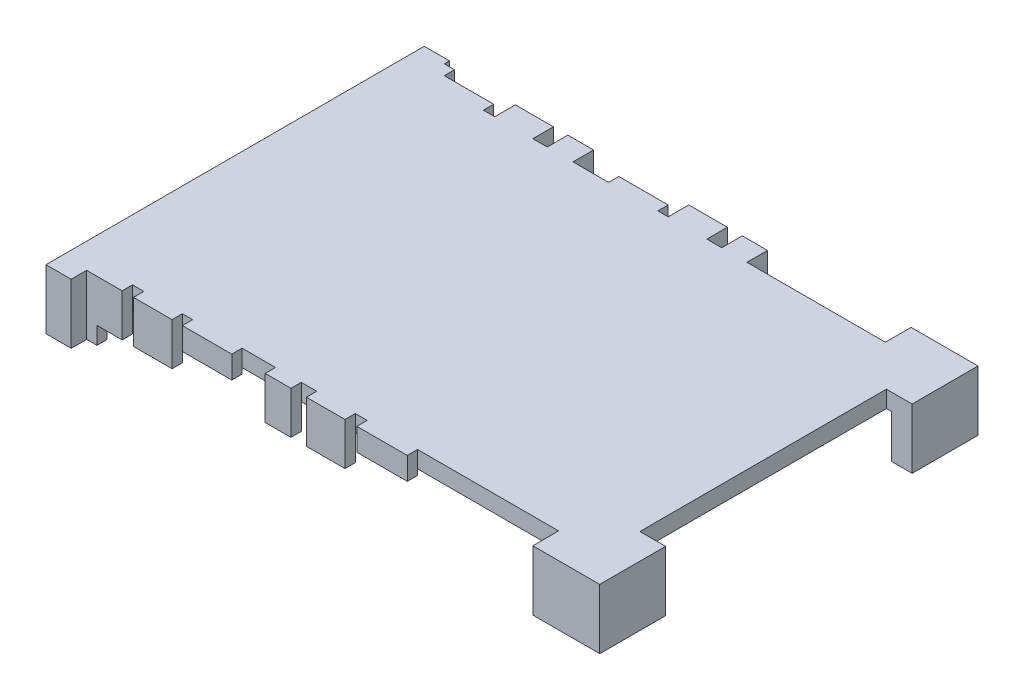
from build123d import *

# Parameters (mm, degrees)
CORNERS_DEPTH                      = 8.4
CORNERS_2_DEPTH                    = 8.4
SKETCH2_W                          = 102.6
SKETCH2_H                          = 63.5
MASTER_DEPTH                       = 3
SKETCH3_W                          = 4.9
SKETCH3_H                          = 73.5
END_TAB_DEPTH                      = 8.36
END_TAB_DEPTH_BACK                 = 3.27
SKETCH4_W                          = 3.2
SKETCH4_H                          = 6.4
MALE_CONNECTORS_DEPTH              = 1.65
SKETCH5_W                          = 9.6
SKETCH5_H                          = 2
SKETCH5_W_2                        = 7.4
SKETCH5_H_2                        = 4
SKETCH5_W_3                        = 5
SKETCH5_W_4                        = 7.5
SKETCH5_W_5                        = 4.9
RIGHT_TERMINALS_DEPTH              = 5
RIGHT_TERMINALS_DEPTH_BACK         = 3.27
SKETCH7_W                          = 4.9
SKETCH7_H                          = 2
LEFT_TERMINALS_DEPTH               = 5
LEFT_TERMINALS_DEPTH_BACK          = 3.27
SKETCH7_W_2                        = 7.5
LEFT_TERMINALS_2_DEPTH             = 5
LEFT_TERMINALS_2_DEPTH_BACK        = 3.27
SKETCH7_W_3                        = 9.6
LEFT_TERMINALS_3_DEPTH             = 5
LEFT_TERMINALS_3_DEPTH_BACK        = 3.27
SKETCH7_W_4                        = 5
LEFT_TERMINALS_4_DEPTH             = 5
LEFT_TERMINALS_4_DEPTH_BACK        = 3.27
LEFT_TERMINALS_5_DEPTH             = 5
LEFT_TERMINALS_5_DEPTH_BACK        = 3.27
SKETCH7_W_5                        = 9.8
LEFT_TERMINALS_6_DEPTH             = 5
LEFT_TERMINALS_6_DEPTH_BACK        = 3.27
SKETCH8_W                          = 9.6
SKETCH8_H                          = 2
GOLD_PLATE_ADJUSTMENTS_RIGHT_DEPTH = 3.9
SKETCH9_W                          = 9.6
SKETCH9_H                          = 2
SKETCH9_W_2                        = 9.8
GOLD_PLATE_ADJUSTMENTS_LEFT_DEPTH  = 3.9
CORNER_ADJUSTMENT_DEPTH            = 3
SKETCH13_W                         = 97.7
SKETCH13_H                         = 63.5
BOSS_EXTRUDE1_DEPTH                = 0.27
SKETCH14_W                         = 13
SKETCH14_H                         = 12.8
BOSS_EXTRUDE2_DEPTH                = 0.27
SKETCH17_W                         = 7.4
SKETCH17_H                         = 2
SKETCH17_W_2                       = 5
SKETCH17_W_3                       = 7.5
SKETCH17_W_4                       = 4.9
CUT_EXTRUDE2_DEPTH                 = 5
SKETCH19_W                         = 15.2
SKETCH19_H                         = 0.4
CUT_EXTRUDE4_DEPTH                 = 0.75
SKETCH20_W                         = 4.9
SKETCH20_H                         = 5
SKETCH20_W_2                       = 7.5
BOSS_EXTRUDE5_DEPTH                = 2.165
SKETCH15_W                         = 2
SKETCH15_H                         = 4
SKETCH15_H_2                       = 2
BOSS_EXTRUDE3_DEPTH                = 11.63
SKETCH21_W                         = 15.3
SKETCH21_H                         = 0.4
CUT_EXTRUDE5_DEPTH                 = 1.65
SKETCH22_W                         = 2
SKETCH22_H                         = 3.074722715
CUT_EXTRUDE7_DEPTH                 = 8.36
SKETCH23_W                         = 9
SKETCH23_H                         = 8.8
CUT_EXTRUDE8_DEPTH                 = 8.4


with BuildPart() as part:
    # Sketch1 → Corners (new body)
    with BuildSketch(Plane(origin=(0, 0, 0), x_dir=(1, 0, 0), z_dir=(0, 1, 0))):
        Polygon((102.6, -63.5), (94.6, -63.5), (94.6, -68.5), (107.6, -68.5), (107.6, -55.7), (102.6, -55.7), align=None)
    extrude(amount=-CORNERS_DEPTH)



with BuildPart() as body_2:
    # Sketch1 → Corners 2 (new body)
    with BuildSketch(Plane(origin=(0, 0, 0), x_dir=(1, 0, 0), z_dir=(0, 1, 0))):
        Polygon((94.6, 5), (94.6, 0), (102.6, 0), (102.6, -7.8), (107.6, -7.8), (107.6, 5), align=None)
    extrude(amount=-CORNERS_2_DEPTH)


with BuildPart() as body_3:
    # Sketch2 → Master (new body)
    with BuildSketch(Plane(origin=(0, 0, 0), x_dir=(1, 0, 0), z_dir=(0, 1, 0))):
        with Locations((51.3, -31.75)):
            Rectangle(SKETCH2_W, SKETCH2_H)
    extrude(amount=MASTER_DEPTH)

    # Sketch3 → End Tab (add, two sides)
    with BuildSketch(Plane.XZ) as end_tab_sk:
        with Locations((2.45, 31.75)):
            Rectangle(SKETCH3_W, SKETCH3_H)
    extrude(amount=END_TAB_DEPTH)
    extrude(end_tab_sk.sketch, amount=-END_TAB_DEPTH_BACK)

    # Sketch4 → Male Connectors (add)
    with BuildSketch(Plane.XZ.offset(8.36)):
        with Locations((3, 12.2)):
            Rectangle(SKETCH4_W, SKETCH4_H)
        with Locations((3, 51.3)):
            Rectangle(SKETCH4_W, SKETCH4_H)
    extrude(amount=MALE_CONNECTORS_DEPTH)

    # Sketch5 → Right Terminals (add, two sides)
    with BuildSketch(Plane.XZ) as right_terminals_sk:
        with Locations((11.7, -1)):
            Rectangle(SKETCH5_W, SKETCH5_H)
        with Locations((22.4, -2)):
            Rectangle(SKETCH5_W_2, SKETCH5_H_2)
        with Locations((31.4, -2)):
            Rectangle(SKETCH5_W_3, SKETCH5_H_2)
        with Locations((45.6, -1)):
            Rectangle(SKETCH5_W, SKETCH5_H)
        with Locations((56.15, -2)):
            Rectangle(SKETCH5_W_4, SKETCH5_H_2)
        with Locations((65.25, -2)):
            Rectangle(SKETCH5_W_5, SKETCH5_H_2)
    extrude(amount=RIGHT_TERMINALS_DEPTH)
    extrude(right_terminals_sk.sketch, amount=-RIGHT_TERMINALS_DEPTH_BACK)

    # Sketch8 → Gold Plate Adjustments (Right) (cut)
    with BuildSketch(Plane.XZ.offset(5)):
        with Locations((11.7, -1)):
            Rectangle(SKETCH8_W, SKETCH8_H)
        with Locations((45.6, -1)):
            Rectangle(SKETCH8_W, SKETCH8_H)
    extrude(amount=-GOLD_PLATE_ADJUSTMENTS_RIGHT_DEPTH, mode=Mode.SUBTRACT)


with BuildPart() as body_4:
    # Sketch7 → Left Terminals (new body, two sides)
    with BuildSketch(Plane.XZ) as left_terminals_sk:
        with Locations((9.35, 64.5)):
            Rectangle(SKETCH7_W, SKETCH7_H)
    extrude(amount=LEFT_TERMINALS_DEPTH)
    extrude(left_terminals_sk.sketch, amount=-LEFT_TERMINALS_DEPTH_BACK)


with BuildPart() as body_5:
    # Sketch7 → Left Terminals 2 (new body, two sides)
    with BuildSketch(Plane.XZ) as left_terminals_2_sk:
        with Locations((17.75, 64.5)):
            Rectangle(SKETCH7_W_2, SKETCH7_H)
    extrude(amount=LEFT_TERMINALS_2_DEPTH)
    extrude(left_terminals_2_sk.sketch, amount=-LEFT_TERMINALS_2_DEPTH_BACK)


with BuildPart() as body_6:
    # Sketch7 → Left Terminals 3 (new body, two sides)
    with BuildSketch(Plane.XZ) as left_terminals_3_sk:
        with Locations((28.3, 64.5)):
            Rectangle(SKETCH7_W_3, SKETCH7_H)
    extrude(amount=LEFT_TERMINALS_3_DEPTH)
    extrude(left_terminals_3_sk.sketch, amount=-LEFT_TERMINALS_3_DEPTH_BACK)


with BuildPart() as body_7:
    # Sketch7 → Left Terminals 4 (new body, two sides)
    with BuildSketch(Plane.XZ) as left_terminals_4_sk:
        with Locations((42.1, 64.5)):
            Rectangle(SKETCH7_W_4, SKETCH7_H)
    extrude(amount=LEFT_TERMINALS_4_DEPTH)
    extrude(left_terminals_4_sk.sketch, amount=-LEFT_TERMINALS_4_DEPTH_BACK)


with BuildPart() as body_8:
    # Sketch7 → Left Terminals 5 (new body, two sides)
    with BuildSketch(Plane.XZ) as left_terminals_5_sk:
        with Locations((51.35, 64.5)):
            Rectangle(SKETCH7_W_2, SKETCH7_H)
    extrude(amount=LEFT_TERMINALS_5_DEPTH)
    extrude(left_terminals_5_sk.sketch, amount=-LEFT_TERMINALS_5_DEPTH_BACK)


with BuildPart() as body_9:
    # Sketch7 → Left Terminals 6 (new body, two sides)
    with BuildSketch(Plane.XZ) as left_terminals_6_sk:
        with Locations((62.3, 64.5)):
            Rectangle(SKETCH7_W_5, SKETCH7_H)
    extrude(amount=LEFT_TERMINALS_6_DEPTH)
    extrude(left_terminals_6_sk.sketch, amount=-LEFT_TERMINALS_6_DEPTH_BACK)


with BuildPart() as gold_plate_adjustments_left_tool:
    # Sketch9 → Gold Plate Adjustments (Left) (new body)
    with BuildSketch(Plane.XZ.offset(5)):
        with Locations((28.3, 64.5)):
            Rectangle(SKETCH9_W, SKETCH9_H)
        with Locations((62.3, 64.5)):
            Rectangle(SKETCH9_W_2, SKETCH9_H)
    extrude(amount=-GOLD_PLATE_ADJUSTMENTS_LEFT_DEPTH)


with BuildPart() as body_6_1:
    add(body_6.part)

    # Gold Plate Adjustments (Left): cut by gold_plate_adjustments_left_tool
    add(gold_plate_adjustments_left_tool.part, mode=Mode.SUBTRACT)


with BuildPart() as body_9_1:
    add(body_9.part)

    # Gold Plate Adjustments (Left): cut by gold_plate_adjustments_left_tool
    add(gold_plate_adjustments_left_tool.part, mode=Mode.SUBTRACT)


with BuildPart() as part_1:
    add(part.part)

    add(body_2.part)  # Corner Adjustment merges body 2

    add(body_3.part)  # Corner Adjustment merges body 3
    # Sketch10 → Corner Adjustment (add)
    with BuildSketch(Plane(origin=(0, 0, 0), x_dir=(1, 0, 0), z_dir=(0, 1, 0))):
        Polygon((102.6, -7.8), (107.6, -7.8), (107.6, 5), (94.6, 5), (94.6, 0), (102.6, 0), align=None)
        Polygon((102.6, -55.7), (107.6, -55.7), (107.6, -68.5), (94.6, -68.5), (94.6, -63.5), (102.6, -63.5), align=None)
    extrude(amount=CORNER_ADJUSTMENT_DEPTH)


    add(body_4.part)  # Boss-Extrude1 merges body 4

    add(body_5.part)  # Boss-Extrude1 merges body 5

    add(body_6_1.part)  # Boss-Extrude1 merges body 6

    add(body_7.part)  # Boss-Extrude1 merges body 7

    add(body_8.part)  # Boss-Extrude1 merges body 8

    add(body_9_1.part)  # Boss-Extrude1 merges body 9
    # Sketch13 → Boss-Extrude1 (add)
    with BuildSketch(Plane(origin=(0, 3, 0), x_dir=(1, 0, 0), z_dir=(0, 1, 0))):
        with Locations((53.75, -31.75)):
            Rectangle(SKETCH13_W, SKETCH13_H)
    extrude(amount=BOSS_EXTRUDE1_DEPTH)

    # Sketch14 → Boss-Extrude2 (add)
    with BuildSketch(Plane(origin=(0, 3, 0), x_dir=(1, 0, 0), z_dir=(0, 1, 0))):
        with Locations((101.1, -62.1)):
            Rectangle(SKETCH14_W, SKETCH14_H)
        with Locations((101.1, -1.4)):
            Rectangle(SKETCH14_W, SKETCH14_H)
    extrude(amount=BOSS_EXTRUDE2_DEPTH)

    # Sketch17 → Cut-Extrude2 (cut)
    with BuildSketch(Plane.XZ.offset(5)):
        with Locations((22.4, -1)):
            Rectangle(SKETCH17_W, SKETCH17_H)
        with Locations((31.4, -1)):
            Rectangle(SKETCH17_W_2, SKETCH17_H)
        with Locations((56.15, -1)):
            Rectangle(SKETCH17_W_3, SKETCH17_H)
        with Locations((65.25, -1)):
            Rectangle(SKETCH17_W_4, SKETCH17_H)
    extrude(amount=-CUT_EXTRUDE2_DEPTH, mode=Mode.SUBTRACT)

    # Sketch19 → Cut-Extrude4 (cut)
    with BuildSketch(Plane(origin=(0, 0, -4), x_dir=(-1, 0, 0), z_dir=(0, 0, -1))):
        with Locations((-26.3, -4.8)):
            Rectangle(SKETCH19_W, SKETCH19_H)
    extrude(amount=-CUT_EXTRUDE4_DEPTH, mode=Mode.SUBTRACT)

    # Sketch20 → Boss-Extrude5 (add)
    with BuildSketch(Plane(origin=(0, 0, -4), x_dir=(-1, 0, 0), z_dir=(0, 0, -1))):
        with Locations((-65.25, -2.5)):
            Rectangle(SKETCH20_W, SKETCH20_H)
        with Locations((-56.15, -2.5)):
            Rectangle(SKETCH20_W_2, SKETCH20_H)
    extrude(amount=-BOSS_EXTRUDE5_DEPTH)

    # Sketch15 → Boss-Extrude3 (add)
    with BuildSketch(Plane(origin=(0, 3.27, 0), x_dir=(1, 0, 0), z_dir=(0, 1, 0))):
        with Locations((5.9, 2)):
            Rectangle(SKETCH15_W, SKETCH15_H)
        with Locations((5.9, -64.5)):
            Rectangle(SKETCH15_W, SKETCH15_H_2)
    extrude(amount=-BOSS_EXTRUDE3_DEPTH)

    # Sketch21 → Cut-Extrude5 (cut)
    with BuildSketch(Plane(origin=(0, 0, -4), x_dir=(-1, 0, 0), z_dir=(0, 0, -1))):
        with Locations((-60.05, -4.8)):
            Rectangle(SKETCH21_W, SKETCH21_H)
    extrude(amount=-CUT_EXTRUDE5_DEPTH, mode=Mode.SUBTRACT)

    # Sketch22 → Cut-Extrude7 (cut)
    with BuildSketch(Plane.XZ.offset(8.36)):
        with Locations((5.9, -1.537361358)):
            Rectangle(SKETCH22_W, SKETCH22_H)
    extrude(amount=-CUT_EXTRUDE7_DEPTH, mode=Mode.SUBTRACT)

    # Sketch23 → Cut-Extrude8 (cut)
    with BuildSketch(Plane.XZ.offset(8.4)):
        with Locations((99.1, 3.4)):
            Rectangle(SKETCH23_W, SKETCH23_H)
    extrude(amount=-CUT_EXTRUDE8_DEPTH, mode=Mode.SUBTRACT)


solid = part_1.part
